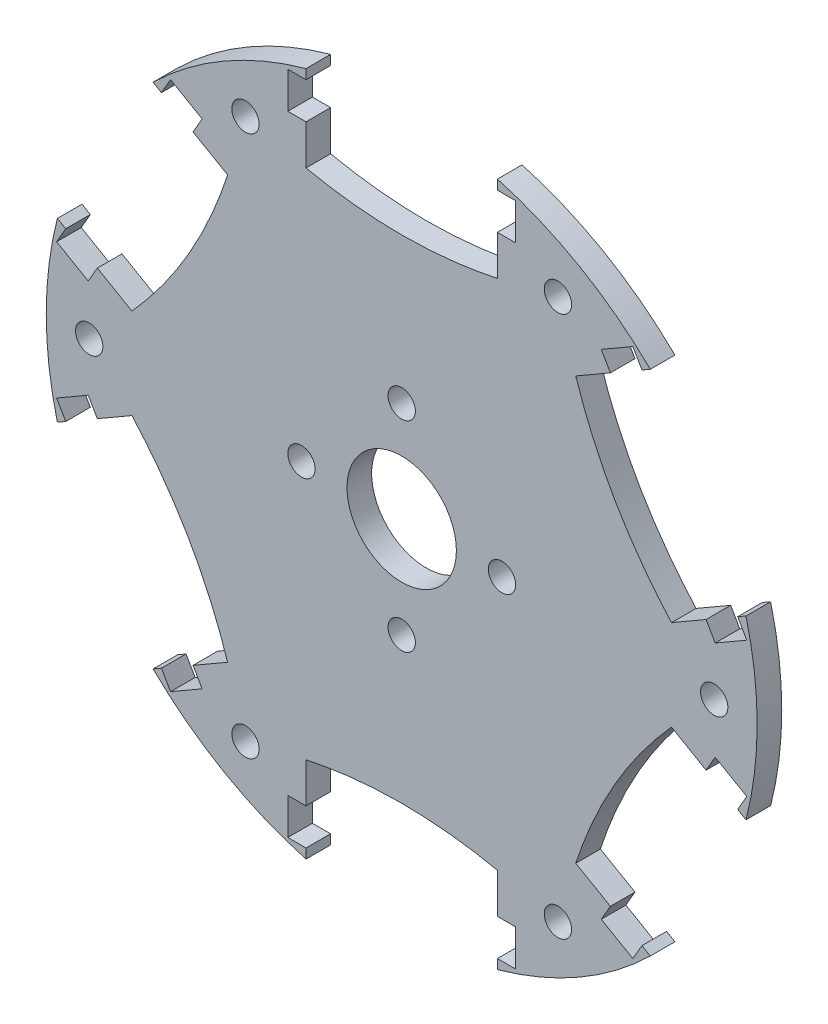
from build123d import *

# Parameters (mm, degrees)
CROQUIS2_R                 = 1.5
CROQUIS2_R_2               = 6
SALIENTE_EXTRUIR2_DEPTH    = 2.7
CROQUIS3_R                 = 1.5
CROQUIS3_W                 = 2
CROQUIS3_H                 = 4
CORTAR_EXTRUIR1_DEPTH      = 1.0000001
CORTAR_EXTRUIR1_DEPTH_BACK = 3.7000001


with BuildPart() as part:
    # Croquis2 → Saliente-Extruir2 (new body)
    with BuildSketch(Plane.XY):
        with BuildLine():
            Line((-10.5, 28.115792599), (-10.5, 37.559952077))
            ThreePointArc((-10.5, 37.559952077), (-19.5, 33.774990748), (-27.277872663, 27.873242778))
            Line((-27.277872663, 27.873242778), (-19.098990638, 23.151163039))
            add(Edge.make_bspline(
                [(-29.598990638, 4.96462956), (-22.416381166, 12.9421037), (-19.098990638, 23.151163039)],
                knots=[0, 0, 0, 1, 1, 1], degree=2))
            Line((-29.598990638, 4.96462956), (-37.777872663, 9.686709299))
            ThreePointArc((-37.777872663, 9.686709299), (-39, 0), (-37.777872663, -9.686709299))
            Line((-37.777872663, -9.686709299), (-29.598990638, -4.96462956))
            add(Edge.make_bspline(
                [(-19.098990638, -23.151163039), (-22.416381166, -12.9421037), (-29.598990638, -4.96462956)],
                knots=[0, 0, 0, 1, 1, 1], degree=2))
            Line((-19.098990638, -23.151163039), (-27.277872663, -27.873242778))
            ThreePointArc((-27.277872663, -27.873242778), (-19.5, -33.774990748), (-10.5, -37.559952077))
            Line((-10.5, -37.559952077), (-10.5, -28.115792599))
            add(Edge.make_bspline(
                [(10.5, -28.115792599), (0, -25.884207401), (-10.5, -28.115792599)],
                knots=[0, 0, 0, 1, 1, 1], degree=2))
            Line((10.5, -28.115792599), (10.5, -37.559952077))
            ThreePointArc((10.5, -37.559952077), (19.5, -33.774990748), (27.277872663, -27.873242778))
            Line((27.277872663, -27.873242778), (19.098990638, -23.151163039))
            add(Edge.make_bspline(
                [(29.598990638, -4.96462956), (22.416381166, -12.9421037), (19.098990638, -23.151163039)],
                knots=[0, 0, 0, 1, 1, 1], degree=2))
            Line((29.598990638, -4.96462956), (37.777872663, -9.686709299))
            ThreePointArc((37.777872663, -9.686709299), (38.693261906, -4.88175), (39, 0))
            ThreePointArc((39, 0), (38.693261906, 4.88175), (37.777872663, 9.686709299))
            Line((37.777872663, 9.686709299), (29.598990638, 4.96462956))
            add(Edge.make_bspline(
                [(19.098990638, 23.151163039), (22.416381166, 12.9421037), (29.598990638, 4.96462956)],
                knots=[0, 0, 0, 1, 1, 1], degree=2))
            Line((19.098990638, 23.151163039), (27.277872663, 27.873242778))
            ThreePointArc((27.277872663, 27.873242778), (19.5, 33.774990748), (10.5, 37.559952077))
            Line((10.5, 37.559952077), (10.5, 28.115792599))
            add(Edge.make_bspline(
                [(-10.5, 28.115792599), (0, 25.884207401), (10.5, 28.115792599)],
                knots=[0, 0, 0, 1, 1, 1], degree=2))
        make_face()
        with Locations((-17.142037335, -29.69087961)):
            Circle(CROQUIS2_R, mode=Mode.SUBTRACT)
        with Locations((-34.28407467, 0)):
            Circle(CROQUIS2_R, mode=Mode.SUBTRACT)
        with Locations((17.142037335, -29.69087961)):
            Circle(CROQUIS2_R, mode=Mode.SUBTRACT)
        with Locations((-17.142037335, 29.69087961)):
            Circle(CROQUIS2_R, mode=Mode.SUBTRACT)
        Circle(CROQUIS2_R_2, mode=Mode.SUBTRACT)
        with Locations((34.28407467, 0)):
            Circle(CROQUIS2_R, mode=Mode.SUBTRACT)
        with Locations((17.142037335, 29.69087961)):
            Circle(CROQUIS2_R, mode=Mode.SUBTRACT)
    extrude(amount=SALIENTE_EXTRUIR2_DEPTH)

    # Croquis3 → Cortar-Extruir1 (cut, two sides)
    with BuildSketch(Plane.XY.offset(2.7)) as cortar_extruir1_sk:
        with Locations((11, 0)):
            Circle(CROQUIS3_R)
        with Locations((0, -11)):
            Circle(CROQUIS3_R)
        with Locations((-11, 0)):
            Circle(CROQUIS3_R)
        with Locations((0, 11)):
            Circle(CROQUIS3_R)
        with Locations((-11.5, 34.5)):
            Rectangle(CROQUIS3_W, CROQUIS3_H)
        with Locations((11.5, 34.5)):
            Rectangle(CROQUIS3_W, CROQUIS3_H)
        Polygon((22.895825623, 25.34326674), (21.895825623, 27.075317547), (25.359927238, 29.075317547), (26.359927238, 27.34326674), align=None)
        Polygon((36.859927238, 9.15673326), (37.859927238, 7.424682453), (34.395825623, 5.424682453), (33.395825623, 7.15673326), align=None)
        Polygon((33.395825623, -7.15673326), (34.395825623, -5.424682453), (37.859927238, -7.424682453), (36.859927238, -9.15673326), align=None)
        Polygon((26.359927238, -27.34326674), (25.359927238, -29.075317547), (21.895825623, -27.075317547), (22.895825623, -25.34326674), align=None)
        with Locations((11.5, -34.5)):
            Rectangle(CROQUIS3_W, CROQUIS3_H)
        with Locations((-11.5, -34.5)):
            Rectangle(CROQUIS3_W, CROQUIS3_H)
        Polygon((-22.895825623, -25.34326674), (-21.895825623, -27.075317547), (-25.359927238, -29.075317547), (-26.359927238, -27.34326674), align=None)
        Polygon((-36.859927238, -9.15673326), (-37.859927238, -7.424682453), (-34.395825623, -5.424682453), (-33.395825623, -7.15673326), align=None)
        Polygon((-33.395825623, 7.15673326), (-34.395825623, 5.424682453), (-37.859927238, 7.424682453), (-36.859927238, 9.15673326), align=None)
        Polygon((-26.359927238, 27.34326674), (-25.359927238, 29.075317547), (-21.895825623, 27.075317547), (-22.895825623, 25.34326674), align=None)
    extrude(amount=CORTAR_EXTRUIR1_DEPTH, mode=Mode.SUBTRACT)
    extrude(cortar_extruir1_sk.sketch, amount=-CORTAR_EXTRUIR1_DEPTH_BACK, mode=Mode.SUBTRACT)


solid = part.part
